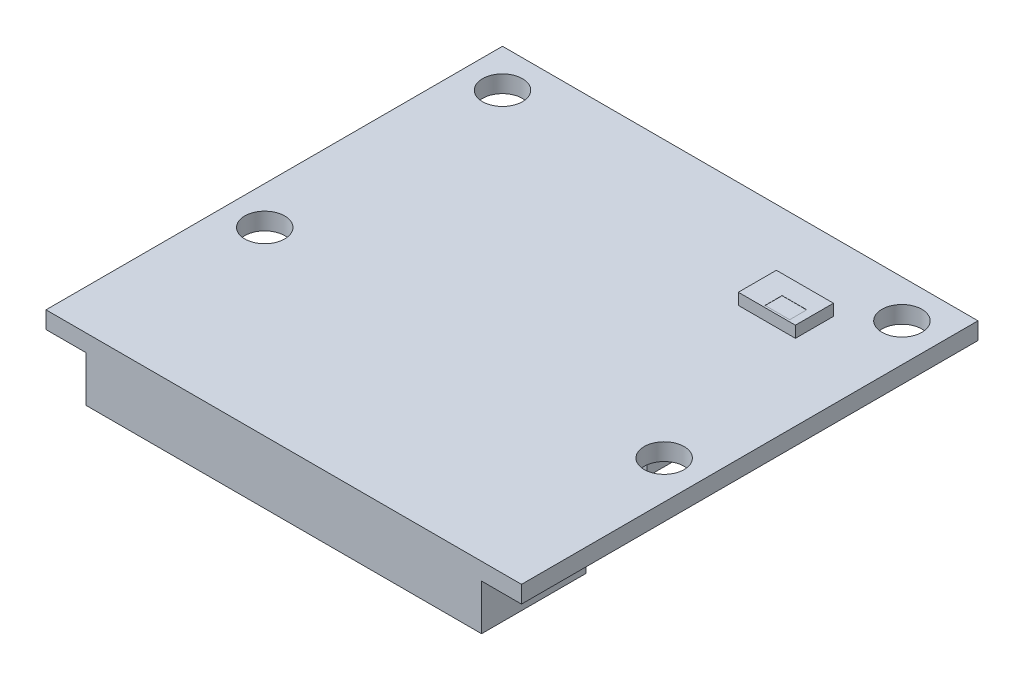
from build123d import *

# Parameters (mm, degrees)
SKIZZE1_W                                 = 25
SKIZZE1_H                                 = 24
PCB_DEPTH                                 = 0.9
SKIZZE2_R                                 = 1.05
MOUNTING_HOLES_DEPTH                      = 1.9
SKIZZE3_W                                 = 20.8
SKIZZE3_H                                 = 5.5
CONNECTOR_CLOSED_DEPTH                    = 2.4
SKIZZE4_W                                 = 17.7
SKIZZE4_H                                 = 11.6
COMPONENTS_WORST_CASE_BOUNDARY_BOX_DEPTH  = 1.3
SKIZZE7_W                                 = 3
SKIZZE7_H                                 = 2
COMPONENTS_WORST_CASE_BOUNDARY_BOX2_DEPTH = 0.6
SKIZZE8_W                                 = 1.3
SKIZZE8_H                                 = 0.9
STATUS_LED_DEPTH                          = 0.01


with BuildPart() as part:
    # Skizze1 → PCB (new body)
    with BuildSketch(Plane(origin=(0, 0, 0), x_dir=(1, 0, 0), z_dir=(0, 1, 0))):
        with Locations((0, 2.5)):
            Rectangle(SKIZZE1_W, SKIZZE1_H)
    extrude(amount=-PCB_DEPTH)

    # Skizze2 → Mounting_Holes (cut, through all)
    with BuildSketch(Plane(origin=(0, 0, 0), x_dir=(1, 0, 0), z_dir=(0, 1, 0))):
        with Locations((10.5, 12.5)):
            Circle(SKIZZE2_R)
        with Locations((10.5, 0)):
            Circle(SKIZZE2_R)
        with Locations((-10.5, 0)):
            Circle(SKIZZE2_R)
        with Locations((-10.5, 12.5)):
            Circle(SKIZZE2_R)
    extrude(amount=-MOUNTING_HOLES_DEPTH, mode=Mode.SUBTRACT)

    # Skizze3 → Connector_closed (add)
    with BuildSketch(Plane.XZ.offset(0.9)):
        with Locations((0, 6.75)):
            Rectangle(SKIZZE3_W, SKIZZE3_H)
    extrude(amount=CONNECTOR_CLOSED_DEPTH)

    # Skizze4 → Components_worst-case_Boundary-Box (add)
    with BuildSketch(Plane.XZ.offset(0.9)):
        with Locations((-0.15, -6.7)):
            Rectangle(SKIZZE4_W, SKIZZE4_H)
    extrude(amount=COMPONENTS_WORST_CASE_BOUNDARY_BOX_DEPTH)

    # Skizze7 → Components_worst-case_Boundary-Box2 (add)
    with BuildSketch(Plane(origin=(0, 0, 0), x_dir=(1, 0, 0), z_dir=(0, 1, 0))):
        with Locations((7, 9.9)):
            Rectangle(SKIZZE7_W, SKIZZE7_H)
    extrude(amount=COMPONENTS_WORST_CASE_BOUNDARY_BOX2_DEPTH)

    # Skizze8 → Status_LED (cut)
    with BuildSketch(Plane(origin=(0, 0.6, 0), x_dir=(1, 0, 0), z_dir=(0, 1, 0))):
        with Locations((7.45, 9.45)):
            Rectangle(SKIZZE8_W, SKIZZE8_H)
    extrude(amount=-STATUS_LED_DEPTH, mode=Mode.SUBTRACT)


solid = part.part
